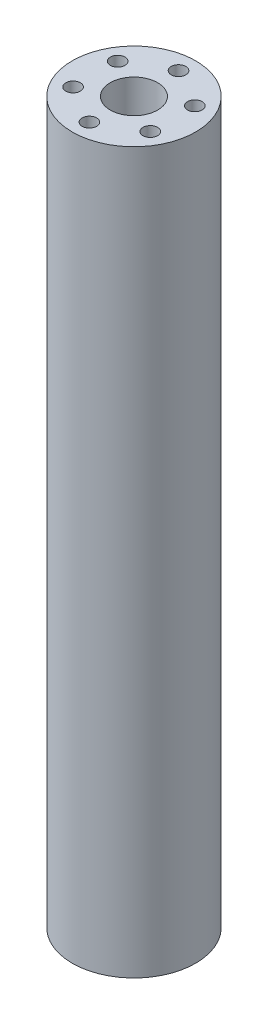
from build123d import *

# Parameters (mm, degrees)
SKETCH1_R           = 18
SKETCH1_R_2         = 2.12769231
SKETCH1_R_3         = 6.9156293
BOSS_EXTRUDE1_DEPTH = 210


with BuildPart() as part:
    # Sketch1 → Boss-Extrude1 (new body)
    with BuildSketch(Plane(origin=(0, 0, 0), x_dir=(1, 0, 0), z_dir=(0, 1, 0))):
        Circle(SKETCH1_R)
        with Locations((0, 13)):
            Circle(SKETCH1_R_2, mode=Mode.SUBTRACT)
        Circle(SKETCH1_R_3, mode=Mode.SUBTRACT)
        with Locations((11.258330249, 6.5)):
            Circle(SKETCH1_R_2, mode=Mode.SUBTRACT)
        with Locations((11.258330249, -6.5)):
            Circle(SKETCH1_R_2, mode=Mode.SUBTRACT)
        with Locations((0, -13)):
            Circle(SKETCH1_R_2, mode=Mode.SUBTRACT)
        with Locations((-11.258330249, -6.5)):
            Circle(SKETCH1_R_2, mode=Mode.SUBTRACT)
        with Locations((-11.258330249, 6.5)):
            Circle(SKETCH1_R_2, mode=Mode.SUBTRACT)
    extrude(amount=BOSS_EXTRUDE1_DEPTH)


solid = part.part
